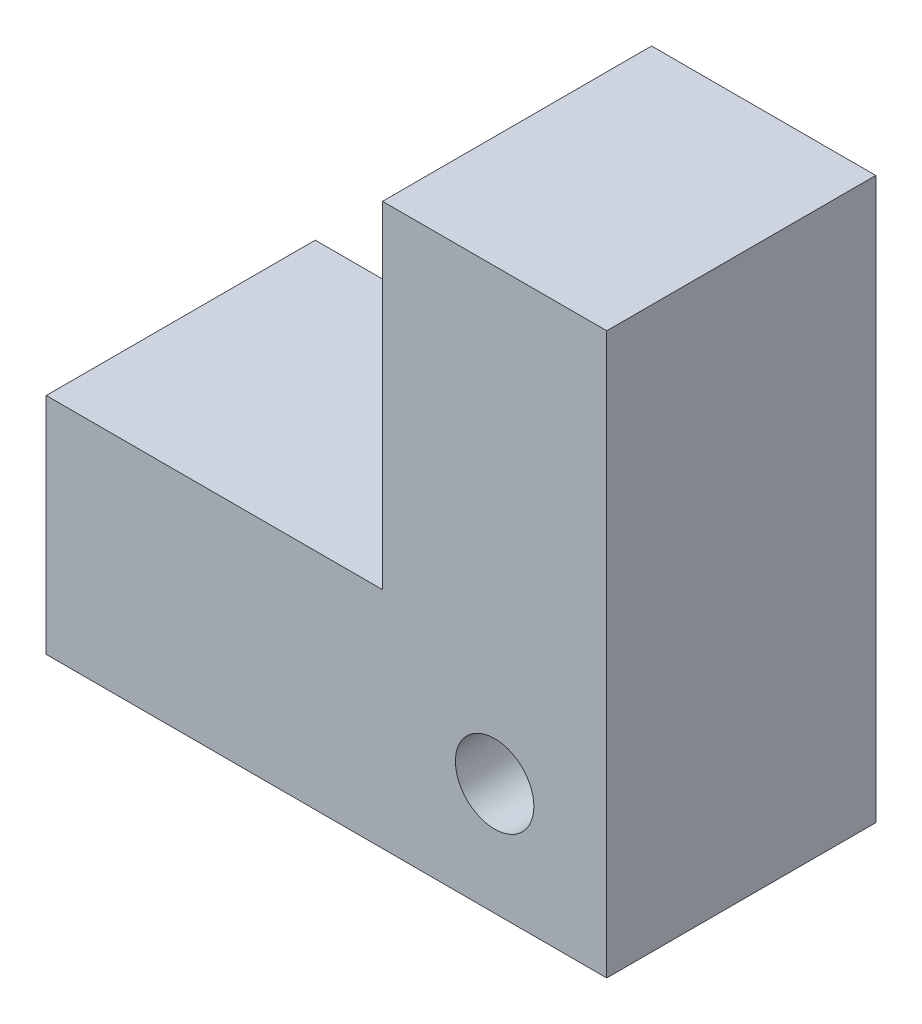
from build123d import *

# Parameters (mm, degrees)
BOSS_EXTRUDE1_DEPTH = 12
SKETCH2_R           = 1.75
CUT_EXTRUDE1_DEPTH  = 13


with BuildPart() as part:
    # Sketch1 → Boss-Extrude1 (new body)
    with BuildSketch(Plane.XY):
        Polygon((0, 0), (0, 25), (-10, 25), (-10, 10), (-25, 10), (-25, 0), align=None)
    extrude(amount=BOSS_EXTRUDE1_DEPTH)

    # Sketch2 → Cut-Extrude1 (cut, through all)
    with BuildSketch(Plane.XY.offset(12)):
        with Locations((-5, 5)):
            Circle(SKETCH2_R)
    extrude(amount=-CUT_EXTRUDE1_DEPTH, mode=Mode.SUBTRACT)


solid = part.part
